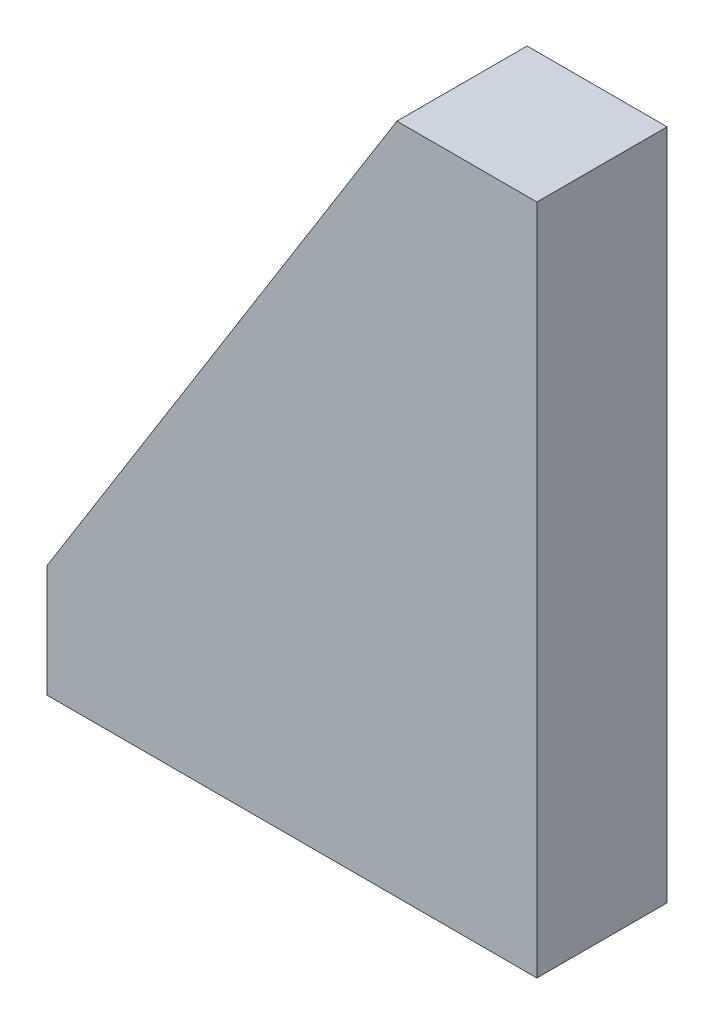
from build123d import *

# Parameters (mm, degrees)
BOSS_EXTRUDE1_DEPTH = 9.3
SKETCH2_W           = 35
SKETCH2_H           = 6
BOSS_EXTRUDE2_DEPTH = 9.3


with BuildPart() as part:
    # Sketch1 → Boss-Extrude1 (new body)
    with BuildSketch(Plane.XY):
        Polygon((0, 0), (0, 42), (-10, 42), (-35, 2), (-35, 0), align=None)
    extrude(amount=-BOSS_EXTRUDE1_DEPTH)

    # Sketch2 → Boss-Extrude2 (add)
    with BuildSketch(Plane.XY):
        with Locations((-17.5, -3)):
            Rectangle(SKETCH2_W, SKETCH2_H)
    extrude(amount=-BOSS_EXTRUDE2_DEPTH)


solid = part.part
